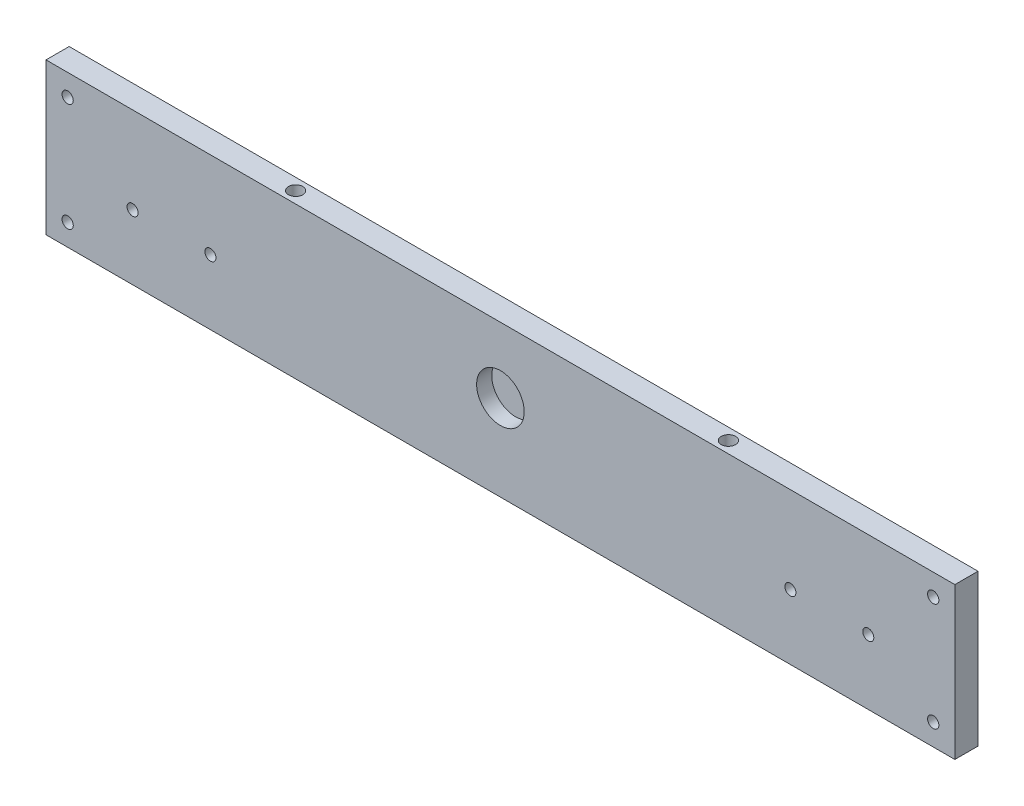
from build123d import *

# Parameters (mm, degrees)
ESBO_O1_W                                   = 420
ESBO_O1_H                                   = 70
RESSALTO_EXTRUS_O1_DEPTH                    = 10.7
ESBO_O5_R                                   = 11
CORTE_EXTRUS_O4_DEPTH                       = 7
FURO_ROSCADO_PARA_CONDU_TE_DE_10_321_D      = 5.1054
FURO_ROSCADO_PARA_CONDU_TE_DE_M5X0_81_D     = 5.2
FURO_ROSCADO_PARA_CONDU_TE_DE_1_4_281_D     = 6.6294
FURO_ROSCADO_PARA_CONDU_TE_DE_1_4_281_DEPTH = 15
FURO_ROSCADO_PARA_CONDU_TE_DE_1_4_281_TIP   = 1.991672694


with BuildPart() as part:
    # Esboço1 → Ressalto-extrusão1 (new body)
    with BuildSketch(Plane.XY):
        Rectangle(ESBO_O1_W, ESBO_O1_H)
    extrude(amount=RESSALTO_EXTRUS_O1_DEPTH)

    # Esboço5 → Corte-extrusão4 (cut)
    with BuildSketch(Plane.XY.offset(10.7)):
        with Locations((0, 4.65)):
            Circle(ESBO_O5_R)
    extrude(amount=-CORTE_EXTRUS_O4_DEPTH, mode=Mode.SUBTRACT)

    # Furo roscado para conduíte de #10-321 (through all)
    with Locations(Plane.XY.offset(10.7)):
        with Locations((-170, -5), (-134, -5), (134, -5), (170, -5)):
            Hole(FURO_ROSCADO_PARA_CONDU_TE_DE_10_321_D / 2)

    # Furo roscado para conduíte de M5x0.81 (through all)
    with Locations(Plane.XY.offset(10.7)):
        with Locations((-200, 25), (-200, -25), (200, -25), (200, 25)):
            Hole(FURO_ROSCADO_PARA_CONDU_TE_DE_M5X0_81_D / 2)

    # Furo roscado para conduíte de 1/4-281
    with Locations(Plane(origin=(0, 35, 0), x_dir=(1, 0, 0), z_dir=(0, 1, 0))):
        with Locations((-100, -5.35), (100, -5.35)):
            Hole(FURO_ROSCADO_PARA_CONDU_TE_DE_1_4_281_D / 2, depth=FURO_ROSCADO_PARA_CONDU_TE_DE_1_4_281_DEPTH)
            with Locations((0, 0, -(FURO_ROSCADO_PARA_CONDU_TE_DE_1_4_281_DEPTH + FURO_ROSCADO_PARA_CONDU_TE_DE_1_4_281_TIP / 2))):  # 118° drill point
                Cone(0, FURO_ROSCADO_PARA_CONDU_TE_DE_1_4_281_D / 2, FURO_ROSCADO_PARA_CONDU_TE_DE_1_4_281_TIP, mode=Mode.SUBTRACT)


solid = part.part
